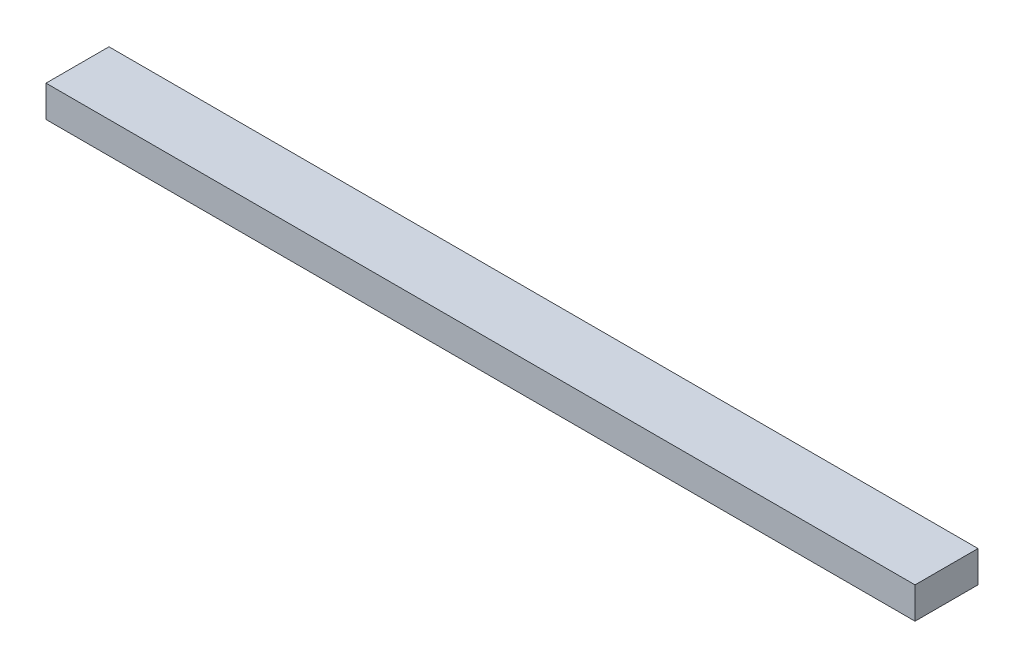
from build123d import *

# Parameters (mm, degrees)
SKETCH1_W           = 175.26
SKETCH1_H           = 12.7
BOSS_EXTRUDE1_DEPTH = 6.35


with BuildPart() as part:
    # Sketch1 → Boss-Extrude1 (new body)
    with BuildSketch(Plane(origin=(0, 0, 0), x_dir=(1, 0, 0), z_dir=(0, 1, 0))):
        Rectangle(SKETCH1_W, SKETCH1_H)
    extrude(amount=BOSS_EXTRUDE1_DEPTH)


solid = part.part
